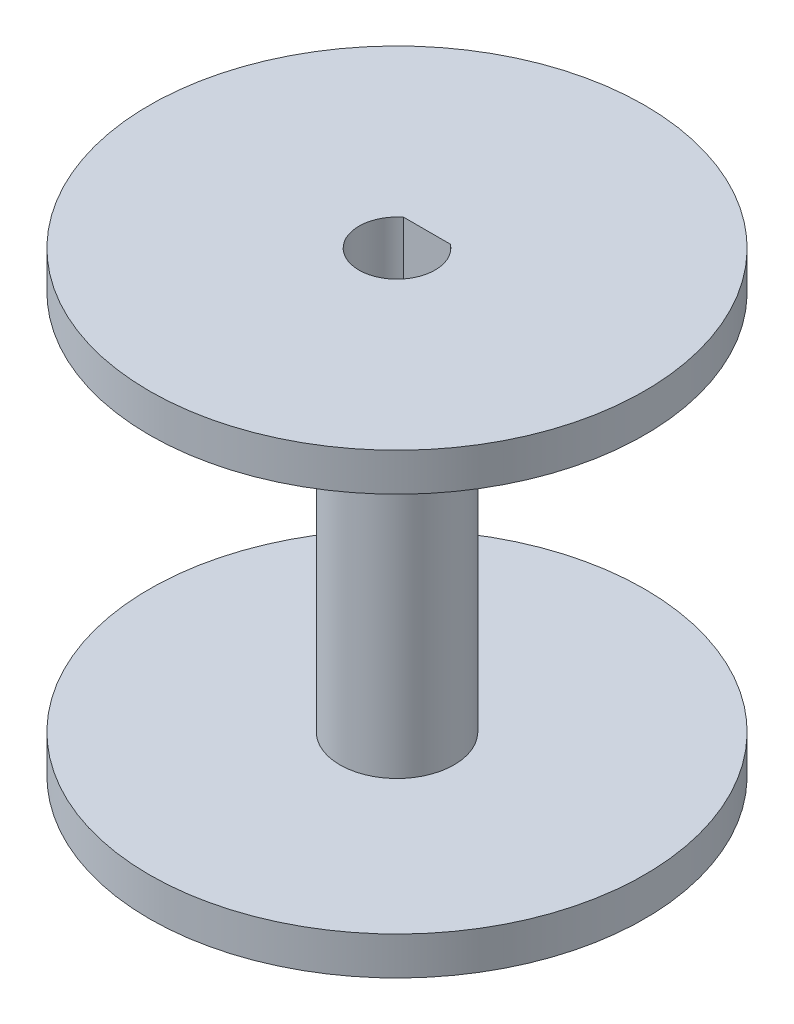
from build123d import *

# Parameters (mm, degrees)
SKETCH1_R           = 33.02
BOSS_EXTRUDE1_DEPTH = 2.54
SKETCH2_R           = 3.81
SKETCH2_R_2         = 2.54
BOSS_EXTRUDE2_DEPTH = 25.4
SKETCH3_R           = 2.54
CUT_EXTRUDE1_DEPTH  = 25.4
SKETCH4_R           = 33.02
BOSS_EXTRUDE3_DEPTH = 2.54
SKETCH5_R           = 2.54
CUT_EXTRUDE2_DEPTH  = 2.54
BOSS_EXTRUDE4_DEPTH = 30.48
SKETCH7_R           = 33.02
SKETCH7_R_2         = 16.51
CUT_EXTRUDE3_DEPTH  = 132.842


with BuildPart() as part:
    # Sketch1 → Boss-Extrude1 (new body)
    with BuildSketch(Plane(origin=(0, 0, 0), x_dir=(1, 0, 0), z_dir=(0, 1, 0))):
        Circle(SKETCH1_R)
    extrude(amount=BOSS_EXTRUDE1_DEPTH)

    # Sketch2 → Boss-Extrude2 (add)
    with BuildSketch(Plane(origin=(0, 2.54, 0), x_dir=(1, 0, 0), z_dir=(0, 1, 0))):
        Circle(SKETCH2_R)
        Circle(SKETCH2_R_2, mode=Mode.SUBTRACT)
    extrude(amount=BOSS_EXTRUDE2_DEPTH)

    # Sketch3 → Cut-Extrude1 (cut)
    with BuildSketch(Plane(origin=(0, 2.54, 0), x_dir=(1, 0, 0), z_dir=(0, 1, 0))):
        Circle(SKETCH3_R)
    extrude(amount=-CUT_EXTRUDE1_DEPTH, mode=Mode.SUBTRACT)

    # Sketch4 → Boss-Extrude3 (add)
    with BuildSketch(Plane(origin=(0, 27.94, 0), x_dir=(1, 0, 0), z_dir=(0, 1, 0))):
        Circle(SKETCH4_R)
    extrude(amount=BOSS_EXTRUDE3_DEPTH)

    # Sketch5 → Cut-Extrude2 (cut)
    with BuildSketch(Plane.XZ.offset(-27.94)):
        Circle(SKETCH5_R)
    extrude(amount=-CUT_EXTRUDE2_DEPTH, mode=Mode.SUBTRACT)

    # Sketch6 → Boss-Extrude4 (add)
    with BuildSketch(Plane(origin=(0, 30.48, 0), x_dir=(1, 0, 0), z_dir=(0, 1, 0))):
        with BuildLine():
            Line((-1.557291379, 2.0066), (0, 2.0066))
            Line((0, 2.0066), (1.557291379, 2.0066))
            ThreePointArc((1.557291379, 2.0066), (0, 2.54), (-1.557291379, 2.0066))
        make_face()
    extrude(amount=-BOSS_EXTRUDE4_DEPTH)

    # Sketch7 → Cut-Extrude3 (cut)
    with BuildSketch(Plane(origin=(0, 30.48, 0), x_dir=(1, 0, 0), z_dir=(0, 1, 0))):
        Circle(SKETCH7_R)
        Circle(SKETCH7_R_2, mode=Mode.SUBTRACT)
    extrude(amount=-CUT_EXTRUDE3_DEPTH, mode=Mode.SUBTRACT)


solid = part.part
